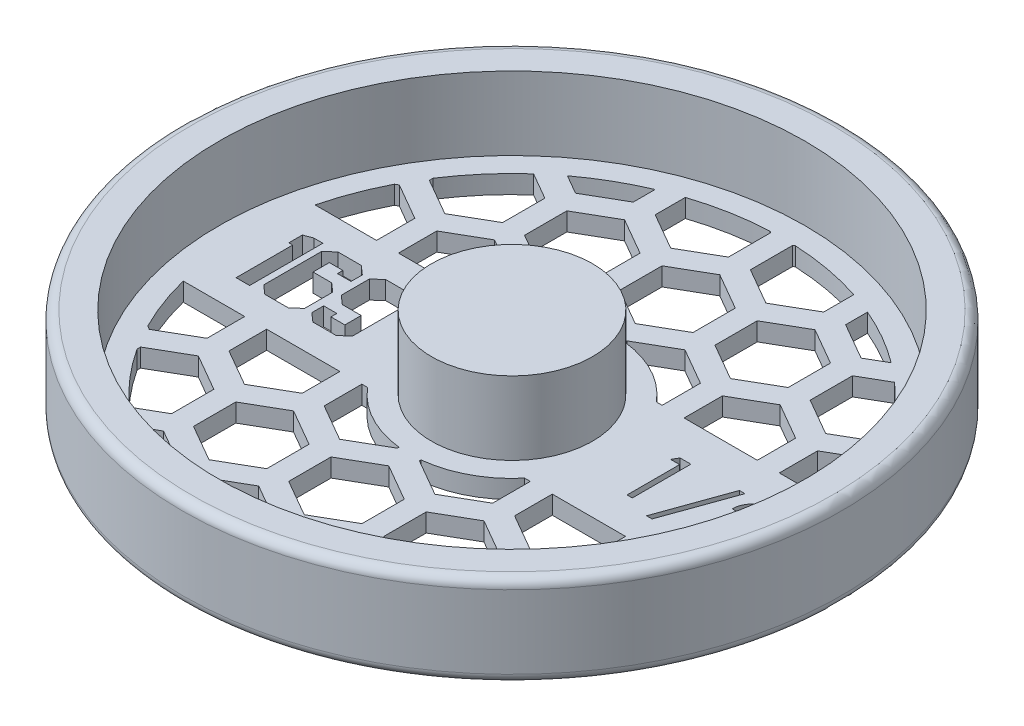
from build123d import *

# Parameters (mm, degrees)
CUT_EXTRUDE2_DEPTH      = 13.7
CUT_EXTRUDE2_DEPTH_BACK = 4.175
CUT_EXTRUDE4_DEPTH      = 13.7
CUT_EXTRUDE4_DEPTH_BACK = 4.1750001


with BuildPart() as part:
    # Sketch1 → Revolve1 (revolve)
    with BuildSketch(Plane.XY):
        with BuildLine():
            Line((0, 0), (0, 15.875))
            Line((0, 15.875), (13.97, 15.875))
            Line((13.97, 15.875), (13.97, 3.175))
            Line((13.97, 3.175), (50.8, 3.175))
            Line((50.8, 3.175), (50.8, 15.875))
            Line((50.8, 15.875), (55.5625, 15.875))
            ThreePointArc((55.5625, 15.875), (56.685032015, 15.410032015), (57.15, 14.2875))
            Line((57.15, 14.2875), (57.15, 1.5875))
            ThreePointArc((57.15, 1.5875), (56.685032015, 0.464967985), (55.5625, 0))
            Line((55.5625, 0), (0, 0))
        make_face()
    revolve(axis=Axis((0, 0, 0), (0, 1, 0)))

    # Sketch3 → Cut-Extrude2 (cut, two sides)
    with BuildSketch(Plane(origin=(0, 3.175, 0), x_dir=(1, 0, 0), z_dir=(0, 1, 0))) as cut_extrude2_sk:
        Polygon((-22.636037344, -5.022991324), (-24.137904564, -6.35), (-28.181208978, -6.35), (-29.68547152, -5.022991324), (-29.68547152, -2.979781215), (-27.397938514, -2.979781215), (-27.397938514, -4.004979253), (-24.978662769, -4.004979253), (-24.978662769, -1.176103357), (-28.253068653, -1.176103357), (-29.750145228, 0.150905319), (-29.750145228, 5.015805356), (-28.253068653, 6.35), (-24.154671822, 6.35), (-22.636037344, 5.008619389), align=None)
        Polygon((-30.945411166, -5.022991324), (-32.449673708, -6.35), (-36.524117314, -6.35), (-38.028379857, -5.022991324), (-38.028379857, 5.015805356), (-36.540884572, 6.35), (-32.473626933, 6.35), (-30.969364391, 5.015805356), (-30.969364391, 3.05164089), (-33.321571105, 3.05164089), (-33.321571105, 4.004979253), (-35.68335911, 4.004979253), (-35.68335911, 1.176103357), (-32.449673708, 1.176103357), (-30.945411166, -0.141324029), align=None)
        Polygon((-39.151786118, -6.35), (-41.496806865, -6.35), (-41.496806865, 3.463636364), (-42.167497171, 3.463636364), (-42.167497171, 5.808657111), (-40.720722369, 6.35), (-39.151786118, 6.35), align=None)
        Polygon((24.058766026, 5.08), (25.937307692, 5.08), (25.937307692, -5.08), (25.025512821, -5.08), (25.025512821, 4.037948718), (23.462435897, 4.037948718), align=None)
        Polygon((35.05525641, 5.340512821), (30.805641026, -6.512820513), (29.845, -6.512820513), (34.094615385, 5.340512821), align=None)
        with BuildLine():
            Line((37.139358974, 1.953846154), (36.227564103, 1.953846154))
            add(Edge.make_bspline(
                [(36.227564103, 1.953846154), (36.233506695, 2.074810788), (36.245177789, 2.31238211), (36.299833623, 2.658762364), (36.378039141, 2.989847152), (36.48861319, 3.302978102), (36.625936557, 3.600923896), (36.790615722, 3.882501085), (36.985669871, 4.146635507), (37.206887133, 4.390878549), (37.447152668, 4.61494304), (37.706395053, 4.808433688), (37.97881376, 4.971915843), (38.263582301, 5.108585962), (38.563913537, 5.211172486), (38.877082062, 5.28729016), (39.204463783, 5.333086638), (39.42751939, 5.338009261), (39.540961538, 5.340512821)],
                knots=[0, 0, 0, 0, 0.000363098, 0.000713115, 0.001050268, 0.001382408, 0.001707501, 0.002033174, 0.002359235, 0.002690688, 0.003020506, 0.003343298, 0.003659183, 0.003972354, 0.004289031, 0.004609402, 0.004938107, 0.005278293, 0.005278293, 0.005278293, 0.005278293], degree=3))
            add(Edge.make_bspline(
                [(39.540961538, 5.340512821), (39.652367605, 5.33790473), (39.871276546, 5.332779925), (40.190770851, 5.288769623), (40.494924368, 5.219839562), (40.783142571, 5.123129668), (41.05312589, 4.993126873), (41.306902499, 4.836960304), (41.547493653, 4.656345022), (41.764066487, 4.443699666), (41.962935654, 4.216689316), (42.134501058, 3.974335859), (42.281423841, 3.724024561), (42.403888649, 3.463846695), (42.494040184, 3.19135251), (42.562484353, 2.910509201), (42.601171931, 2.61840975), (42.607109503, 2.420706149), (42.610128205, 2.320192308)],
                knots=[0, 0, 0, 0, 0.000334086, 0.000656467, 0.000965531, 0.001268675, 0.001566359, 0.001862361, 0.002161551, 0.002466703, 0.002771129, 0.003065925, 0.003355997, 0.003641006, 0.003926769, 0.004215553, 0.004507135, 0.00480869, 0.00480869, 0.00480869, 0.00480869], degree=3))
            add(Edge.make_bspline(
                [(42.610128205, 2.320192308), (42.605212905, 2.178684308), (42.595468561, 1.898151573), (42.512114828, 1.485902715), (42.381931813, 1.086488675), (42.2251852, 0.765034107), (42.067059477, 0.506002022), (41.924565455, 0.292732867), (41.757753317, 0.063100993), (41.564195163, -0.182124649), (41.34789494, -0.444864876), (41.10689346, -0.724960968), (40.839472152, -1.01951902), (40.651777762, -1.22070328), (40.554519231, -1.324951923)],
                knots=[0, 0, 0, 0, 0.000424159, 0.000840875, 0.001256646, 0.001681742, 0.001910017, 0.002166855, 0.002451012, 0.002761254, 0.003103933, 0.003471932, 0.003869646, 0.004297365, 0.004297365, 0.004297365, 0.004297365], degree=3))
            Line((40.554519231, -1.324951923), (38.012483974, -4.037948718))
            Line((38.012483974, -4.037948718), (42.740384615, -4.037948718))
            Line((42.740384615, -4.037948718), (42.740384615, -5.08))
            Line((42.740384615, -5.08), (35.836794872, -5.08))
            Line((35.836794872, -5.08), (39.777051282, -0.875160256))
            add(Edge.make_bspline(
                [(39.777051282, -0.875160256), (39.872984576, -0.775016601), (40.057252801, -0.582661133), (40.317878796, -0.301830141), (40.551962259, -0.041300045), (40.761018462, 0.198436907), (40.940512295, 0.420887401), (41.099798545, 0.618846883), (41.227424375, 0.801014088), (41.365935352, 1.012169698), (41.500087938, 1.269979168), (41.615367235, 1.585036963), (41.68565948, 1.909365216), (41.694091803, 2.128536844), (41.698333333, 2.238782051)],
                knots=[0, 0, 0, 0, 0.000416034, 0.000799117, 0.001149329, 0.001466777, 0.001753177, 0.002006834, 0.002228761, 0.00242014, 0.002764237, 0.003097746, 0.003424264, 0.003754734, 0.003754734, 0.003754734, 0.003754734], degree=3))
            add(Edge.make_bspline(
                [(41.698333333, 2.238782051), (41.696487864, 2.308106339), (41.692850799, 2.444731199), (41.660751883, 2.645045059), (41.612243671, 2.838273204), (41.542734008, 3.025009996), (41.450984156, 3.203377946), (41.339301431, 3.373594174), (41.210443418, 3.538154142), (41.061378019, 3.692450573), (40.897623436, 3.833765158), (40.724629843, 3.958948217), (40.541604397, 4.063564607), (40.349318785, 4.149325159), (40.14830908, 4.21659998), (39.938186506, 4.263215742), (39.719531647, 4.292483752), (39.570227557, 4.296443749), (39.494150641, 4.298461538)],
                knots=[0, 0, 0, 0, 0.000207845, 0.000409623, 0.000607075, 0.000804788, 0.001005949, 0.001207481, 0.001414728, 0.001632081, 0.001849968, 0.002062903, 0.002271673, 0.002481215, 0.002693605, 0.002906413, 0.003126042, 0.003354217, 0.003354217, 0.003354217, 0.003354217], degree=3))
            add(Edge.make_bspline(
                [(39.494150641, 4.298461538), (39.414697024, 4.296385902), (39.258663238, 4.292309695), (39.02957256, 4.263795904), (38.811028703, 4.21460455), (38.602481921, 4.147325976), (38.403579352, 4.061812017), (38.215288299, 3.955301124), (38.038031455, 3.828203898), (37.871475604, 3.684104454), (37.718019025, 3.523670503), (37.583190379, 3.344825582), (37.465380784, 3.150835142), (37.362592838, 2.942222618), (37.279119177, 2.717095074), (37.215334261, 2.476251679), (37.164862728, 2.220738183), (37.148001423, 2.044287766), (37.139358974, 1.953846154)],
                knots=[0, 0, 0, 0, 0.000238342, 0.000468065, 0.000691248, 0.000909439, 0.00112457, 0.001339654, 0.001557083, 0.001777841, 0.001999544, 0.002221797, 0.002448333, 0.00267953, 0.002918453, 0.003167288, 0.003426342, 0.003698747, 0.003698747, 0.003698747, 0.003698747], degree=3))
        make_face()
    extrude(amount=CUT_EXTRUDE2_DEPTH, mode=Mode.SUBTRACT)
    extrude(cut_extrude2_sk.sketch, amount=-CUT_EXTRUDE2_DEPTH_BACK, mode=Mode.SUBTRACT)

    # Sketch4 → Cut-Extrude4 (cut, two sides)
    with BuildSketch(Plane(origin=(0, 3.175, 0), x_dir=(1, 0, 0), z_dir=(0, 1, 0))) as cut_extrude4_sk:
        with BuildLine():
            Line((-45.57867045, 11.43), (-34.925, 11.43))
            Line((-34.925, 11.43), (-34.925, 18.070094793))
            Line((-34.925, 18.070094793), (-41.275, 21.736269002))
            Line((-41.275, 21.736269002), (-41.824450692, 21.419043498))
            ThreePointArc((-41.824450692, 21.419043498), (-43.986039192, 16.531438418), (-45.57867045, 11.43))
        make_face()
        Polygon((-31.115, 11.43), (-18.415, 11.43), (-18.415, 18.070094793), (-24.765, 21.736269002), (-31.115, 18.070094793), align=None)
        with BuildLine():
            ThreePointArc((-31.304627771, 35.043977801), (-35.647925291, 30.61511918), (-39.37, 25.652742543))
            Line((-39.37, 25.652742543), (-39.37, 25.035825791))
            Line((-39.37, 25.035825791), (-33.02, 21.369651581))
            Line((-33.02, 21.369651581), (-26.67, 25.035825791))
            Line((-26.67, 25.035825791), (-26.67, 32.368174209))
            Line((-26.67, 32.368174209), (-31.304627771, 35.043977801))
        make_face()
        with BuildLine():
            ThreePointArc((-18.415, 43.231329785), (-23.408586329, 40.744302498), (-28.072243454, 37.683010063))
            Line((-28.072243454, 37.683010063), (-24.765, 35.773572165))
            Line((-24.765, 35.773572165), (-18.415, 39.439746374))
            Line((-18.415, 39.439746374), (-18.415, 43.231329785))
        make_face()
        Polygon((-16.51, 36.034348419), (-22.86, 32.368174209), (-22.86, 25.035825791), (-16.51, 21.369651581), (-10.16, 25.035825791), (-10.16, 32.368174209), align=None)
        with BuildLine():
            Line((-1.905, 46.772094793), (-2.193684728, 46.938766998))
            ThreePointArc((-2.193684728, 46.938766998), (-8.476090298, 46.21921671), (-14.605, 44.662669815))
            Line((-14.605, 44.662669815), (-14.605, 39.439746374))
            Line((-14.605, 39.439746374), (-8.255, 35.773572165))
            Line((-8.255, 35.773572165), (-1.905, 39.439746374))
            Line((-1.905, 39.439746374), (-1.905, 46.772094793))
        make_face()
        Polygon((-6.35, 25.035825791), (0, 21.369651581), (6.35, 25.035825791), (6.35, 32.368174209), (0, 36.034348419), (-6.35, 32.368174209), align=None)
        with BuildLine():
            ThreePointArc((-13.619232724, 11.43), (-8.367122494, 15.688201336), (-1.905, 17.677651852))
            Line((-1.905, 17.677651852), (-1.905, 18.070094793))
            Line((-1.905, 18.070094793), (-8.255, 21.736269002))
            Line((-8.255, 21.736269002), (-14.605, 18.070094793))
            Line((-14.605, 18.070094793), (-14.605, 11.43))
            Line((-14.605, 11.43), (-13.619232724, 11.43))
        make_face()
        with BuildLine():
            ThreePointArc((1.905, 17.677651852), (8.367122494, 15.688201336), (13.619232724, 11.43))
            Line((13.619232724, 11.43), (14.605, 11.43))
            Line((14.605, 11.43), (14.605, 18.070094793))
            Line((14.605, 18.070094793), (8.255, 21.736269002))
            Line((8.255, 21.736269002), (1.905, 18.070094793))
            Line((1.905, 18.070094793), (1.905, 17.677651852))
        make_face()
        with BuildLine():
            Line((14.605, 39.439746374), (14.605, 44.662669815))
            ThreePointArc((14.605, 44.662669815), (8.476090298, 46.21921671), (2.193684728, 46.938766998))
            Line((2.193684728, 46.938766998), (1.905, 46.772094793))
            Line((1.905, 46.772094793), (1.905, 39.439746374))
            Line((1.905, 39.439746374), (8.255, 35.773572165))
            Line((8.255, 35.773572165), (14.605, 39.439746374))
        make_face()
        Polygon((16.51, 36.034348419), (10.16, 32.368174209), (10.16, 25.035825791), (16.51, 21.369651581), (22.86, 25.035825791), (22.86, 32.368174209), align=None)
        with BuildLine():
            Line((24.765, 35.773572165), (28.072243454, 37.683010063))
            ThreePointArc((28.072243454, 37.683010063), (23.408586329, 40.744302498), (18.415, 43.231329785))
            Line((18.415, 43.231329785), (18.415, 39.439746374))
            Line((18.415, 39.439746374), (24.765, 35.773572165))
        make_face()
        with BuildLine():
            Line((39.37, 25.035825791), (39.37, 25.652742543))
            ThreePointArc((39.37, 25.652742543), (35.647925291, 30.61511918), (31.304627771, 35.043977801))
            Line((31.304627771, 35.043977801), (26.67, 32.368174209))
            Line((26.67, 32.368174209), (26.67, 25.035825791))
            Line((26.67, 25.035825791), (33.02, 21.369651581))
            Line((33.02, 21.369651581), (39.37, 25.035825791))
        make_face()
        Polygon((18.415, 18.070094793), (18.415, 11.43), (31.115, 11.43), (31.115, 18.070094793), (24.765, 21.736269002), align=None)
        with BuildLine():
            Line((34.925, 18.070094793), (34.925, 11.43))
            Line((34.925, 11.43), (45.57867045, 11.43))
            ThreePointArc((45.57867045, 11.43), (43.986039192, 16.531438418), (41.824450692, 21.419043498))
            Line((41.824450692, 21.419043498), (41.275, 21.736269002))
            Line((41.275, 21.736269002), (34.925, 18.070094793))
        make_face()
        with BuildLine():
            Line((45.57867045, -11.43), (34.925, -11.43))
            Line((34.925, -11.43), (34.925, -17.964253626))
            Line((34.925, -17.964253626), (41.275, -21.630427835))
            Line((41.275, -21.630427835), (41.900926719, -21.269048875))
            ThreePointArc((41.900926719, -21.269048875), (44.01558475, -16.452610707), (45.57867045, -11.43))
        make_face()
        Polygon((31.115, -11.43), (18.415, -11.43), (18.415, -17.964253626), (24.765, -21.630427835), (31.115, -17.964253626), align=None)
        with BuildLine():
            Line((14.605, -11.43), (13.619232724, -11.43))
            ThreePointArc((13.619232724, -11.43), (8.367122494, -15.688201336), (1.905, -17.677651852))
            Line((1.905, -17.677651852), (1.905, -17.964253626))
            Line((1.905, -17.964253626), (8.255, -21.630427835))
            Line((8.255, -21.630427835), (14.605, -17.964253626))
            Line((14.605, -17.964253626), (14.605, -11.43))
        make_face()
        with BuildLine():
            ThreePointArc((31.304627771, -35.043977801), (35.647925291, -30.61511918), (39.37, -25.652742543))
            Line((39.37, -25.652742543), (39.37, -25.035825791))
            Line((39.37, -25.035825791), (33.02, -21.369651581))
            Line((33.02, -21.369651581), (26.67, -25.035825791))
            Line((26.67, -25.035825791), (26.67, -32.368174209))
            Line((26.67, -32.368174209), (31.304627771, -35.043977801))
        make_face()
        with BuildLine():
            ThreePointArc((18.415, -43.231329785), (23.451826011, -40.719429721), (28.152186338, -37.623323942))
            Line((28.152186338, -37.623323942), (24.765, -35.667730998))
            Line((24.765, -35.667730998), (18.415, -39.333905207))
            Line((18.415, -39.333905207), (18.415, -43.231329785))
        make_face()
        Polygon((16.51, -21.369651581), (10.16, -25.035825791), (10.16, -32.368174209), (16.51, -36.034348419), (22.86, -32.368174209), (22.86, -25.035825791), align=None)
        with BuildLine():
            ThreePointArc((2.362789552, -46.930558547), (8.559339951, -46.203872128), (14.605, -44.662669815))
            Line((14.605, -44.662669815), (14.605, -39.333905207))
            Line((14.605, -39.333905207), (8.255, -35.667730998))
            Line((8.255, -35.667730998), (1.905, -39.333905207))
            Line((1.905, -39.333905207), (1.905, -46.666253626))
            Line((1.905, -46.666253626), (2.362789552, -46.930558547))
        make_face()
        Polygon((-6.35, -32.368174209), (0, -36.034348419), (6.35, -32.368174209), (6.35, -25.035825791), (0, -21.369651581), (-6.35, -25.035825791), align=None)
        with BuildLine():
            ThreePointArc((-14.605, -44.662669815), (-8.559339951, -46.203872128), (-2.362789552, -46.930558547))
            Line((-2.362789552, -46.930558547), (-1.905, -46.666253626))
            Line((-1.905, -46.666253626), (-1.905, -39.333905207))
            Line((-1.905, -39.333905207), (-8.255, -35.667730998))
            Line((-8.255, -35.667730998), (-14.605, -39.333905207))
            Line((-14.605, -39.333905207), (-14.605, -44.662669815))
        make_face()
        Polygon((-16.51, -21.369651581), (-22.86, -25.035825791), (-22.86, -32.368174209), (-16.51, -36.034348419), (-10.16, -32.368174209), (-10.16, -25.035825791), align=None)
        with BuildLine():
            Line((-24.765, -35.667730998), (-28.152186338, -37.623323942))
            ThreePointArc((-28.152186338, -37.623323942), (-23.451826011, -40.719429721), (-18.415, -43.231329785))
            Line((-18.415, -43.231329785), (-18.415, -39.333905207))
            Line((-18.415, -39.333905207), (-24.765, -35.667730998))
        make_face()
        with BuildLine():
            Line((-39.37, -25.035825791), (-39.37, -25.652742543))
            ThreePointArc((-39.37, -25.652742543), (-35.647925291, -30.61511918), (-31.304627771, -35.043977801))
            Line((-31.304627771, -35.043977801), (-26.67, -32.368174209))
            Line((-26.67, -32.368174209), (-26.67, -25.035825791))
            Line((-26.67, -25.035825791), (-33.02, -21.369651581))
            Line((-33.02, -21.369651581), (-39.37, -25.035825791))
        make_face()
        with BuildLine():
            Line((-34.925, -17.964253626), (-34.925, -11.43))
            Line((-34.925, -11.43), (-45.57867045, -11.43))
            ThreePointArc((-45.57867045, -11.43), (-44.01558475, -16.452610707), (-41.900926719, -21.269048875))
            Line((-41.900926719, -21.269048875), (-41.275, -21.630427835))
            Line((-41.275, -21.630427835), (-34.925, -17.964253626))
        make_face()
        Polygon((-18.415, -17.964253626), (-18.415, -11.43), (-31.115, -11.43), (-31.115, -17.964253626), (-24.765, -21.630427835), align=None)
        with BuildLine():
            Line((-1.905, -17.964253626), (-1.905, -17.677651852))
            ThreePointArc((-1.905, -17.677651852), (-8.367122494, -15.688201336), (-13.619232724, -11.43))
            Line((-13.619232724, -11.43), (-14.605, -11.43))
            Line((-14.605, -11.43), (-14.605, -17.964253626))
            Line((-14.605, -17.964253626), (-8.255, -21.630427835))
            Line((-8.255, -21.630427835), (-1.905, -17.964253626))
        make_face()
    extrude(amount=CUT_EXTRUDE4_DEPTH, mode=Mode.SUBTRACT)
    extrude(cut_extrude4_sk.sketch, amount=-CUT_EXTRUDE4_DEPTH_BACK, mode=Mode.SUBTRACT)


solid = part.part
